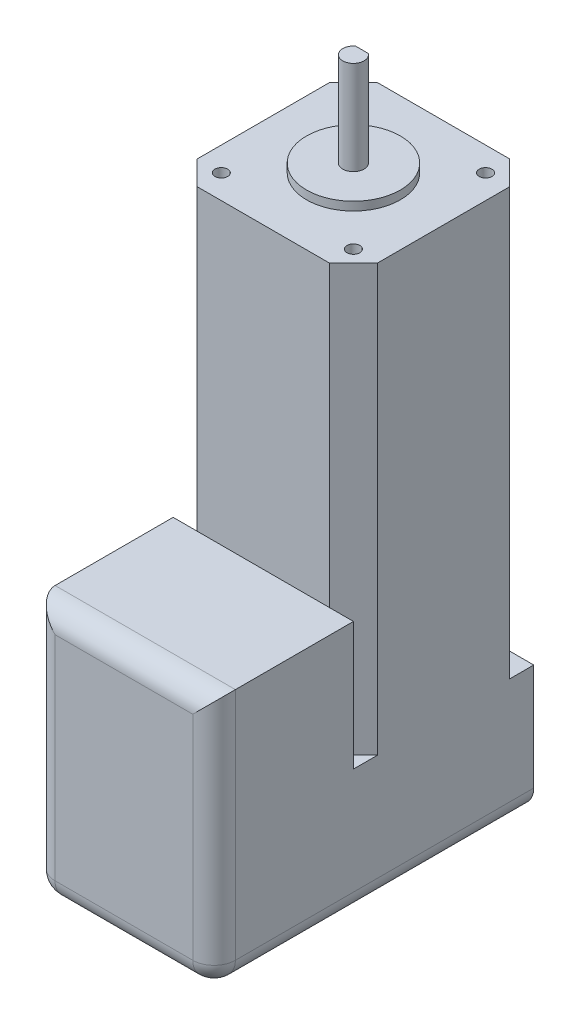
from build123d import *

# Parameters (mm, degrees)
SKETCH1_R           = 1.5
BOSS_EXTRUDE1_DEPTH = 15
BOSS_EXTRUDE2_DEPTH = 85
SKETCH3_R           = 11
BOSS_EXTRUDE3_DEPTH = 2
SKETCH4_R           = 2.5
BOSS_EXTRUDE4_DEPTH = 22
CUT_EXTRUDE1_DEPTH  = 15
SKETCH6_W           = 42.3
SKETCH6_H           = 75
BOSS_EXTRUDE5_DEPTH = 30
SKETCH7_W           = 42.3
SKETCH7_H           = 32.7
BOSS_EXTRUDE6_DEPTH = 30
FILLET1_R           = 5


with BuildPart() as part:
    # Sketch1 → Boss-Extrude1 (new body)
    with BuildSketch(Plane(origin=(0, 0, 0), x_dir=(1, 0, 0), z_dir=(0, 1, 0))):
        Polygon((5.65, 0), (36.65, 0), (42.3, 5.65), (42.3, 36.65), (36.65, 42.3), (5.65, 42.3), (0, 36.65), (0, 5.65), align=None)
        with Locations((5.65, 5.65)):
            Circle(SKETCH1_R, mode=Mode.SUBTRACT)
        with Locations((36.65, 5.65)):
            Circle(SKETCH1_R, mode=Mode.SUBTRACT)
        with Locations((36.65, 36.65)):
            Circle(SKETCH1_R, mode=Mode.SUBTRACT)
        with Locations((5.65, 36.65)):
            Circle(SKETCH1_R, mode=Mode.SUBTRACT)
    extrude(amount=BOSS_EXTRUDE1_DEPTH)

    # Sketch2 → Boss-Extrude2 (add)
    with BuildSketch(Plane.XZ):
        Polygon((5.65, 0), (0, -5.65), (0, -36.65), (5.65, -42.3), (36.65, -42.3), (42.3, -36.65), (42.3, -5.65), (36.65, 0), align=None)
    extrude(amount=BOSS_EXTRUDE2_DEPTH)

    # Sketch3 → Boss-Extrude3 (add)
    with BuildSketch(Plane(origin=(0, 15, 0), x_dir=(1, 0, 0), z_dir=(0, 1, 0))):
        with Locations((21.15, 21.15)):
            Circle(SKETCH3_R)
    extrude(amount=BOSS_EXTRUDE3_DEPTH)

    # Sketch4 → Boss-Extrude4 (add)
    with BuildSketch(Plane(origin=(0, 17, 0), x_dir=(1, 0, 0), z_dir=(0, 1, 0))):
        with Locations((21.15, 21.15)):
            Circle(SKETCH4_R)
    extrude(amount=BOSS_EXTRUDE4_DEPTH)

    # Sketch5 → Cut-Extrude1 (cut)
    with BuildSketch(Plane(origin=(0, 39, 0), x_dir=(1, 0, 0), z_dir=(0, 1, 0))):
        with BuildLine():
            Line((19.65, 23.15), (22.65, 23.15))
            ThreePointArc((22.65, 23.15), (21.15, 23.65), (19.65, 23.15))
        make_face()
    extrude(amount=-CUT_EXTRUDE1_DEPTH, mode=Mode.SUBTRACT)

    # Sketch6 → Boss-Extrude5 (add)
    with BuildSketch(Plane.XZ.offset(85)):
        with Locations((21.15, -4.8)):
            Rectangle(SKETCH6_W, SKETCH6_H)
    extrude(amount=BOSS_EXTRUDE5_DEPTH)

    # Sketch7 → Boss-Extrude6 (add)
    with BuildSketch(Plane(origin=(0, -85, 0), x_dir=(1, 0, 0), z_dir=(0, 1, 0))):
        with Locations((21.15, -16.35)):
            Rectangle(SKETCH7_W, SKETCH7_H)
    extrude(amount=BOSS_EXTRUDE6_DEPTH)

    # Fillet1
    fillet1_edges = [part.edges().sort_by_distance(p)[0] for p in [
        (21.15, -55, 32.7),
        (42.3, -85, 32.7),
        (0, -85, 32.7),
        (42.3, -115, -4.8),
        (21.15, -115, 32.7),
        (0, -115, -4.8),
    ]]
    fillet(fillet1_edges, radius=FILLET1_R)


solid = part.part
